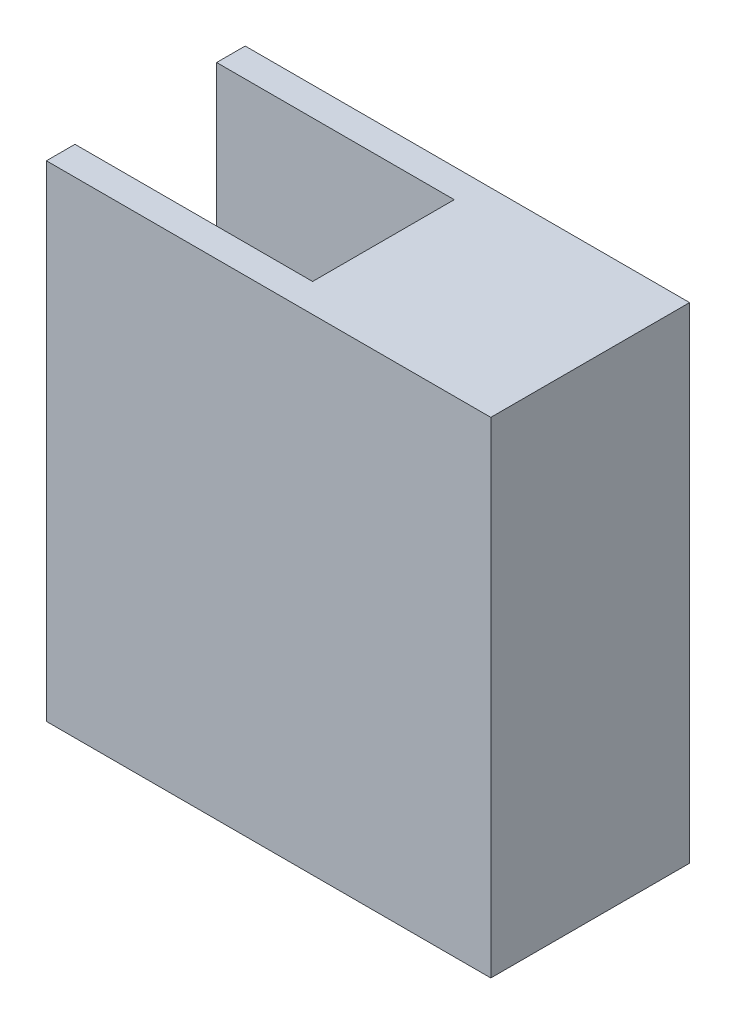
from build123d import *

# Parameters (mm, degrees)
BOSS_EXTRUDE3_DEPTH = 11.557
SKETCH3_W           = 11.049
SKETCH3_H           = 26.9875
BOSS_EXTRUDE4_DEPTH = 1.5875
CUT_EXTRUDE1_REACH  = 28.988
SKETCH4_W           = 13.208
SKETCH4_H           = 7.874


with BuildPart() as part:
    # Sketch1 → Boss-Extrude3 (new body, symmetric)
    with BuildSketch(Plane(origin=(0, 0, 0), x_dir=(0, 0, -1), z_dir=(1, 0, 0))):
        Polygon((-5.5245, -13.49375), (-3.937, -13.49375), (-3.937, 11.90625), (3.937, 11.90625), (3.937, 3.65125), (0.508, 3.65125), (0.508, -11.58875), (-1.651, -11.58875), (-1.651, -13.49375), (5.5245, -13.49375), (5.5245, 13.49375), (-5.5245, 13.49375), align=None)
    extrude(amount=BOSS_EXTRUDE3_DEPTH, both=True)

    # Sketch3 → Boss-Extrude4 (add)
    with BuildSketch(Plane(origin=(11.557, 0, 0), x_dir=(0, 0, -1), z_dir=(1, 0, 0))):
        Rectangle(SKETCH3_W, SKETCH3_H)
    extrude(amount=BOSS_EXTRUDE4_DEPTH)

    # Sketch4 → Cut-Extrude1 (cut, up to next)
    with BuildSketch(Plane(origin=(0, 13.49375, 0), x_dir=(1, 0, 0), z_dir=(0, 1, 0)), mode=Mode.PRIVATE) as cut_extrude1_sk1:
        with Locations((-4.953, 0)):
            Rectangle(SKETCH4_W, SKETCH4_H)
    cut_extrude1_tool1 = extrude(cut_extrude1_sk1.sketch, amount=-CUT_EXTRUDE1_REACH, mode=Mode.PRIVATE) & part.part
    add(cut_extrude1_tool1.solids().sort_by_distance((-4.953, 13.49375, 0))[0], mode=Mode.SUBTRACT)


solid = part.part
